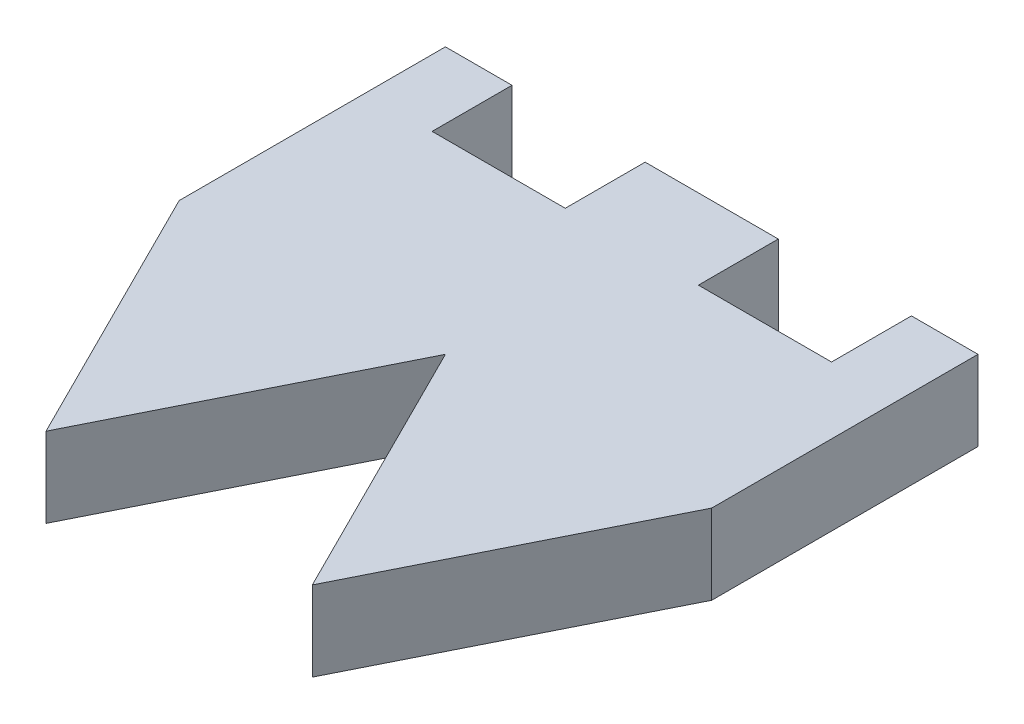
from build123d import *

# Parameters (mm, degrees)
SKETCH1_W               = 20
SKETCH1_H               = 20
BOSS_EXTRUDE1_DEPTH     = 3
CUT_EXTRUDE1_DEPTH      = 1
CUT_EXTRUDE1_DEPTH_BACK = 4
CUT_EXTRUDE2_START      = -4
SKETCH3_W               = 5
SKETCH3_H               = 3
CUT_EXTRUDE2_DEPTH      = 5


with BuildPart() as part:
    # Sketch1 → Boss-Extrude1 (new body)
    with BuildSketch(Plane(origin=(0, 0, 0), x_dir=(1, 0, 0), z_dir=(0, 1, 0))):
        Rectangle(SKETCH1_W, SKETCH1_H)
    extrude(amount=BOSS_EXTRUDE1_DEPTH)

    # Sketch2 → Cut-Extrude1 (cut, two sides)
    with BuildSketch(Plane(origin=(0, 3, 0), x_dir=(1, 0, 0), z_dir=(0, 1, 0))) as cut_extrude1_sk:
        Polygon((-5, -10), (-10, 0), (-10, -10), align=None)
        Polygon((0, 0), (-5, -10), (5, -10), align=None)
        Polygon((10, 0), (5, -10), (10, -10), align=None)
    extrude(amount=CUT_EXTRUDE1_DEPTH, mode=Mode.SUBTRACT)
    extrude(cut_extrude1_sk.sketch, amount=-CUT_EXTRUDE1_DEPTH_BACK, mode=Mode.SUBTRACT)

    # Sketch3 → Cut-Extrude2 (cut)
    with BuildSketch(Plane(origin=(0, 3, 0), x_dir=(1, 0, 0), z_dir=(0, 1, 0)).offset(CUT_EXTRUDE2_START)):
        with Locations((-5, 8.5)):
            Rectangle(SKETCH3_W, SKETCH3_H)
    cut_extrude2 = extrude(amount=CUT_EXTRUDE2_DEPTH, mode=Mode.SUBTRACT)

    # Mirror1: Cut-Extrude2 across plane
    add(cut_extrude2.mirror(Plane(origin=(0, 0, 0), x_dir=(0, 0, 1), z_dir=(1, 0, 0))), mode=Mode.SUBTRACT)


solid = part.part
